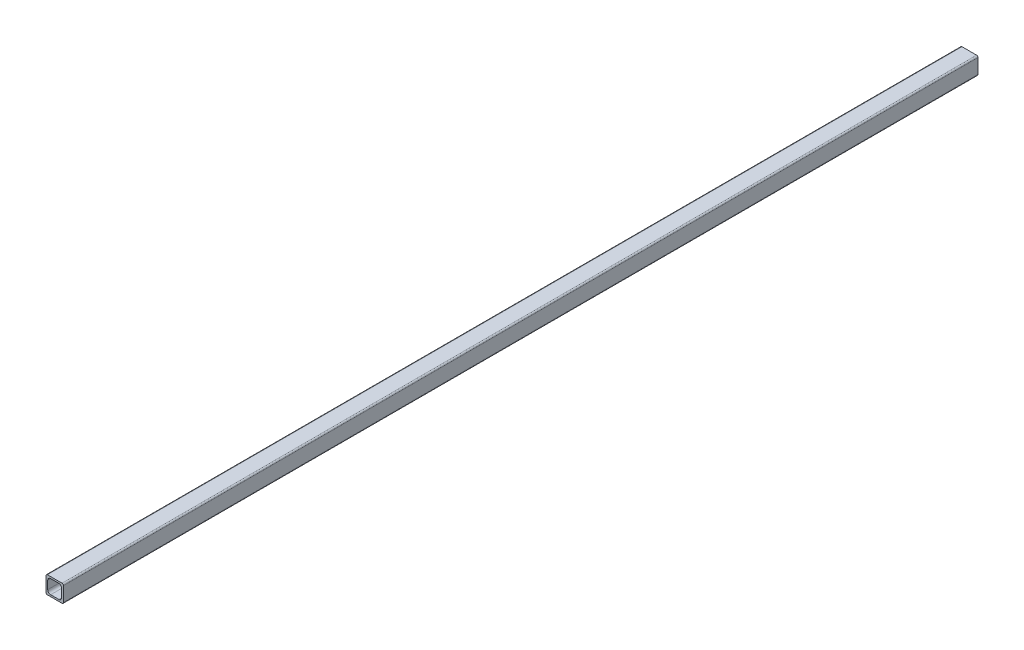
from build123d import *

# Parameters (mm, degrees)
BOSS_EXTRUDE1_DEPTH = 1000.125
CUT_EXTRUDE1_DEPTH  = 1001.125


with BuildPart() as part:
    # Sketch1 → Boss-Extrude1 (new body)
    with BuildSketch(Plane.XY):
        with BuildLine():
            Line((1.524, 0), (17.526, 0))
            ThreePointArc((17.526, 0), (18.603630735, 0.446369265), (19.05, 1.524))
            Line((19.05, 1.524), (19.05, 17.526))
            ThreePointArc((19.05, 17.526), (18.603630735, 18.603630735), (17.526, 19.05))
            Line((17.526, 19.05), (1.524, 19.05))
            ThreePointArc((1.524, 19.05), (0.446369265, 18.603630735), (0, 17.526))
            Line((0, 17.526), (0, 1.524))
            ThreePointArc((0, 1.524), (0.446369265, 0.446369265), (1.524, 0))
        make_face()
    extrude(amount=-BOSS_EXTRUDE1_DEPTH)

    # Sketch2 → Cut-Extrude1 (cut, through all)
    with BuildSketch(Plane.XY):
        with BuildLine():
            Line((5.08, 17.145), (13.97, 17.145))
            ThreePointArc((13.97, 17.145), (16.21506403, 16.21506403), (17.145, 13.97))
            Line((17.145, 13.97), (17.145, 5.08))
            ThreePointArc((17.145, 5.08), (16.21506403, 2.83493597), (13.97, 1.905))
            Line((13.97, 1.905), (5.08, 1.905))
            ThreePointArc((5.08, 1.905), (2.83493597, 2.83493597), (1.905, 5.08))
            Line((1.905, 5.08), (1.905, 13.97))
            ThreePointArc((1.905, 13.97), (2.83493597, 16.21506403), (5.08, 17.145))
        make_face()
    extrude(amount=-CUT_EXTRUDE1_DEPTH, mode=Mode.SUBTRACT)


solid = part.part
